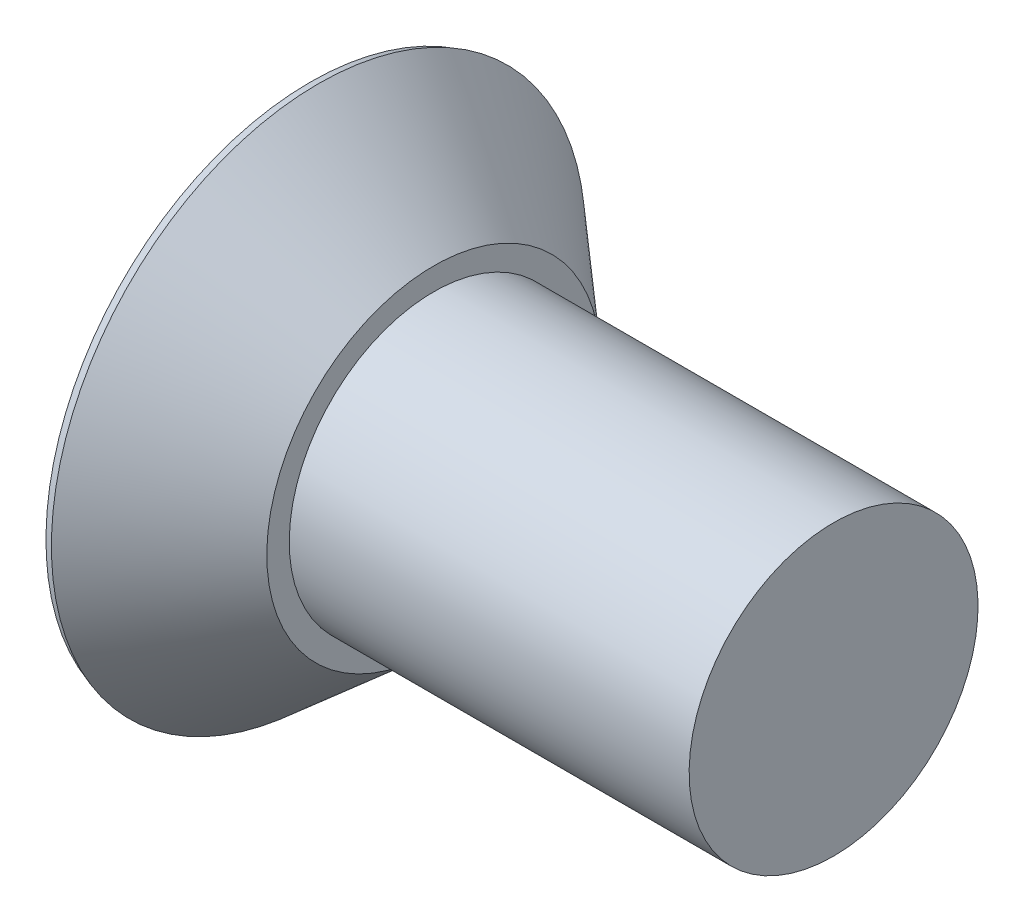
from build123d import *

# Parameters (mm, degrees)
CUT_EXTRUDE1_REACH = 9.904
CIRPATTERN1_COUNT  = 4
DRAFT1_ANGLE       = 5
CHAMFER1_SIZE      = 0.133096
CHAMFER1_SIZE2     = 0.121906137


with BuildPart() as part:
    # Sketch2 → Revolve1 (revolve)
    with BuildSketch(Plane.XY, mode=Mode.PRIVATE) as revolve1_sk:
        Polygon((-3.175, 0), (3.175, 0), (3.175, 1.7526), (-1.6764, 1.7526), (-1.6764, 2.024686895), (-3.175, 3.3274), align=None)
    revolve(revolve1_sk.sketch.rotate(Axis((-3.175, 0, 0), (1, 0, 0)), 180), axis=Axis((-3.175, 0, 0), (1, 0, 0)))

    # Cut-Extrude1: up to this cone (the profile starts inside it)
    cut_extrude1_end = Plane(origin=(-3.175, 0, 0), z_dir=(-1, 0, 0)).offset(-2.137134931) * Cone(1e-06, 12.516790067, 14.398918853, align=(Align.CENTER, Align.CENTER, Align.MIN), mode=Mode.PRIVATE)
    # Sketch3 → Cut-Extrude1 (cut, up to the surface)
    with BuildSketch(Plane.ZY.offset(3.175), mode=Mode.PRIVATE) as cut_extrude1_sk1:
        with BuildLine():
            Line((0, 0), (2.218266667, 0))
            ThreePointArc((2.218266667, 0), (2.207033704, 0.22295568), (2.173448579, 0.443653333))
            Line((2.173448579, 0.443653333), (1.308550956, 0.443653333))
            Line((1.308550956, 0.443653333), (0.696975982, 0.696975982))
            Line((0.696975982, 0.696975982), (0.443653333, 1.308550956))
            Line((0.443653333, 1.308550956), (0.443653333, 2.173448579))
            ThreePointArc((0.443653333, 2.173448579), (0.22295568, 2.207033704), (0, 2.218266667))
            Line((0, 2.218266667), (0, 0))
        make_face()
    cut_extrude1_tool1 = extrude(cut_extrude1_sk1.sketch, amount=-CUT_EXTRUDE1_REACH, mode=Mode.PRIVATE) & cut_extrude1_end
    cut_extrude1 = cut_extrude1_tool1.solids().sort_by_distance((-3.175, 1.109133, 0.031371))[0]
    add(cut_extrude1, mode=Mode.SUBTRACT)

    # CirPattern1: Cut-Extrude1 ×4 about axis
    cirpattern1_axis = Axis((0, 0, 0), (1, 0, 0))
    for i in range(1, CIRPATTERN1_COUNT):
        add(cut_extrude1.rotate(cirpattern1_axis, i * 360 / CIRPATTERN1_COUNT), mode=Mode.SUBTRACT)

    # Draft1
    draft1_faces = [part.faces().sort_by_distance(p)[0] for p in [
        (-2.99204002, 0.443653333, -1.474018435),
        (-2.764573893, 0.582482874, -0.973386795),
        (-2.764573893, 0.973386795, -0.582482874),
        (-2.99204002, 1.474018435, -0.443653333),
        (-2.99204002, 1.474018435, 0.443653333),
        (-2.764573893, 0.973386795, 0.582482874),
        (-2.764573893, 0.582482874, 0.973386795),
        (-2.99204002, 0.443653333, 1.474018435),
        (-2.99204002, -0.443653333, 1.474018435),
        (-2.764573893, -0.582482874, 0.973386795),
        (-2.764573893, -0.973386795, 0.582482874),
        (-2.99204002, -1.474018435, 0.443653333),
        (-2.99204002, -1.474018435, -0.443653333),
        (-2.764573893, -0.973386795, -0.582482874),
        (-2.764573893, -0.582482874, -0.973386795),
        (-2.99204002, -0.443653333, -1.474018435),
    ]]
    draft(draft1_faces, Plane(origin=(-3.175, 0, 0), x_dir=(0, -1, 0), z_dir=(-1, 0, 0)), DRAFT1_ANGLE)

    # Chamfer1
    chamfer1_edges = [part.edges().sort_by_distance(p)[0] for p in [
        (-3.175, 3.3274, 0),
    ]]
    chamfer1_side = [part.faces().sort_by_distance(p)[0] for p in [
        (-2.4257, 2.676043447, 0),
    ]]
    chamfer(chamfer1_edges, length=CHAMFER1_SIZE, length2=CHAMFER1_SIZE2, reference=chamfer1_side[0])


solid = part.part
